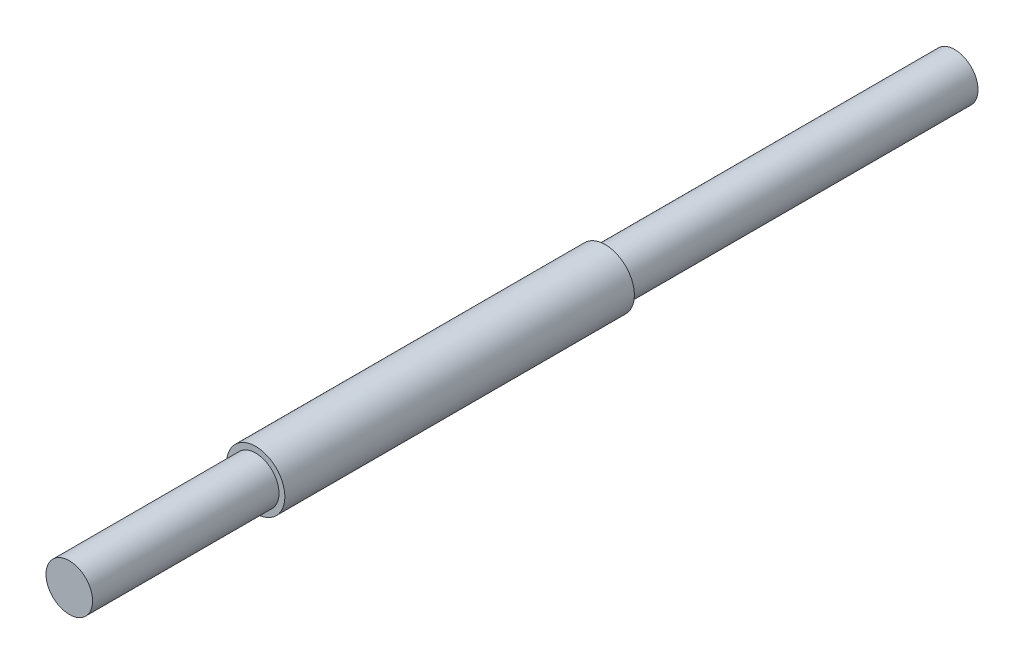
from build123d import *

# Parameters (mm, degrees)
CROQUIS1_R              = 10
SALIENTE_EXTRUIR1_DEPTH = 80
CROQUIS2_R              = 12.5
SALIENTE_EXTRUIR2_DEPTH = 150
CROQUIS3_R              = 10
SALIENTE_EXTRUIR3_DEPTH = 150


with BuildPart() as part:
    # Croquis1 → Saliente-Extruir1 (new body)
    with BuildSketch(Plane.XY):
        Circle(CROQUIS1_R)
    extrude(amount=SALIENTE_EXTRUIR1_DEPTH)

    # Croquis2 → Saliente-Extruir2 (add)
    with BuildSketch(Plane(origin=(0, 0, 0), x_dir=(-1, 0, 0), z_dir=(0, 0, -1))):
        Circle(CROQUIS2_R)
    extrude(amount=SALIENTE_EXTRUIR2_DEPTH)

    # Croquis3 → Saliente-Extruir3 (add)
    with BuildSketch(Plane(origin=(0, 0, -150), x_dir=(-1, 0, 0), z_dir=(0, 0, -1))):
        Circle(CROQUIS3_R)
    extrude(amount=SALIENTE_EXTRUIR3_DEPTH)


solid = part.part
